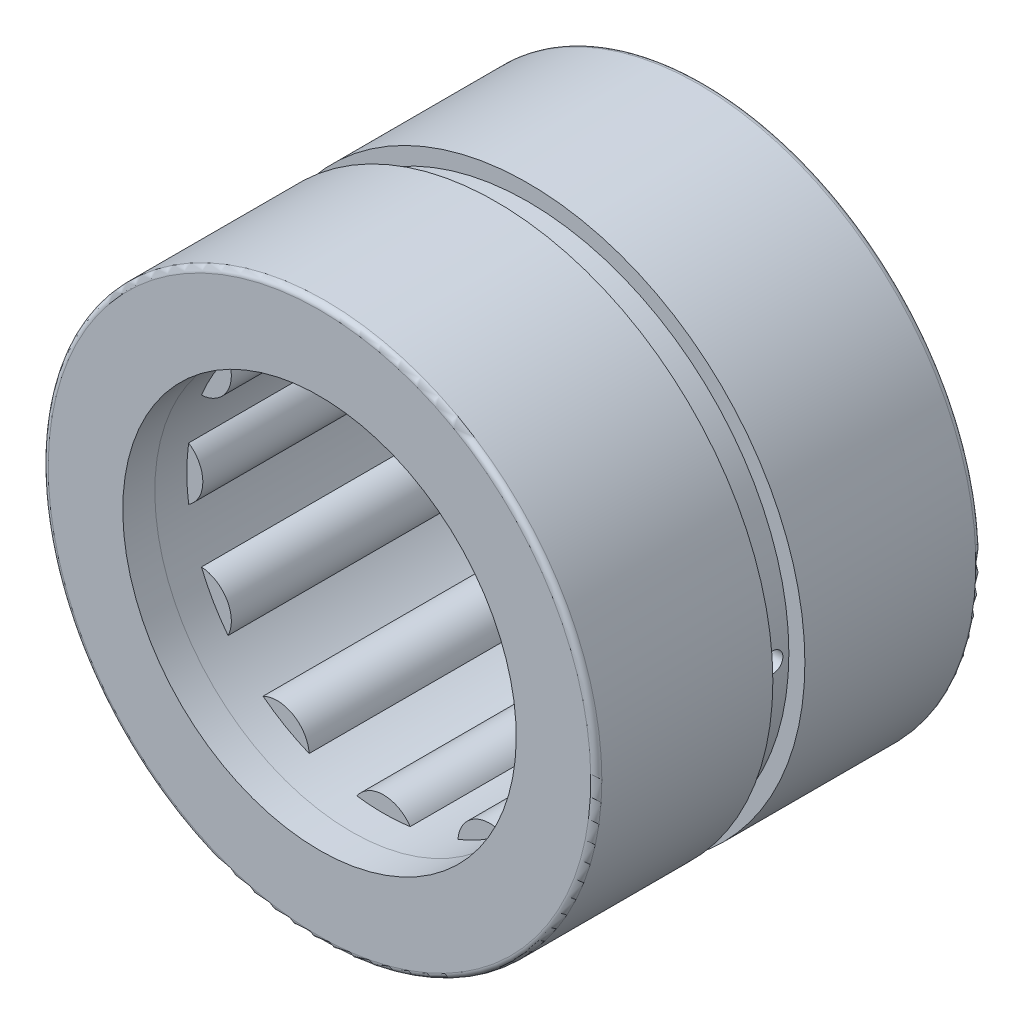
from build123d import *

# Parameters (mm, degrees)
SKETCH2_W           = 10.677333334
SKETCH2_H           = 0.998
SKETCH3_W           = 13.338666666
SKETCH3_H           = 0.332666666
CIRPATTERN1_COUNT   = 12
CIRPATTERN1_ANGLE   = 330
FILLET1_R           = 0.23
SKETCH5_R           = 10.269333333
SKETCH5_R_2         = 8.173333333
BOSS_EXTRUDE1_DEPTH = 13.338667
SKETCH2_4_W         = 10.677333334
SKETCH2_4_H         = 0.998
CIRPATTERN2_COUNT   = 12
SKETCH7_W           = 1.330666666
SKETCH7_H           = 0.665333333
SKETCH8_R           = 0.416666667
CUT_EXTRUDE2_DEPTH  = 12.5


with BuildPart() as part:
    # Sketch1 → Revolve1 (revolve)
    with BuildSketch(Plane(origin=(0, 0, 0), x_dir=(0, 0, -1), z_dir=(1, 0, 0))):
        Polygon((-8, 11.5), (8, 11.5), (8, 8.173333333), (6.669333333, 8.173333333), (6.669333333, 10.169333333), (-6.669333333, 10.169333333), (-6.669333333, 8.173333333), (-8, 8.173333333), align=None)
    revolve(axis=Axis((0, 0, 8), (0, 0, -1)))

    # Fillet1
    fillet1_edges = [part.edges().sort_by_distance(p)[0] for p in [
        (0, -11.5, 8),
        (0, -11.5, -8),
    ]]
    fillet(fillet1_edges, radius=FILLET1_R)

    # Sketch4 → Cut-Revolve1 (revolve, cut)
    with BuildSketch(Plane(origin=(0, 0, 0), x_dir=(0, 0, -1), z_dir=(1, 0, 0))):
        Polygon((-0.665333333, 11.5), (0, 10.834666667), (0.665333333, 11.5), align=None)
    revolve(axis=Axis((0, 0, 8), (0, 0, -1)), mode=Mode.SUBTRACT)

    # Sketch7 → Cut-Revolve4 (revolve, cut)
    with BuildSketch(Plane(origin=(0, 0, 0), x_dir=(0, 0, -1), z_dir=(1, 0, 0))):
        with Locations((0, 11.167333334)):
            Rectangle(SKETCH7_W, SKETCH7_H)
    revolve(axis=Axis((0, 0, 35.715394286), (0, 0, -1)), mode=Mode.SUBTRACT)

    # Sketch8 → Cut-Extrude2 (cut, through all)
    with BuildSketch(Plane(origin=(0, 0, 0), x_dir=(0, 0, -1), z_dir=(1, 0, 0))):
        Circle(SKETCH8_R)
    extrude(amount=CUT_EXTRUDE2_DEPTH, mode=Mode.SUBTRACT)


with BuildPart() as body_2:
    # Sketch2 → Revolve2 (revolve)
    with BuildSketch(Plane(origin=(0, 0, 0), x_dir=(0, 0, -1), z_dir=(1, 0, 0))):
        with Locations((0, 9.670333333)):
            Rectangle(SKETCH2_W, SKETCH2_H)
    revolve(axis=Axis((0, 8.838666667, 5.338666667), (0, 0, -1)))


with BuildPart() as body_3:
    # Sketch3 → Revolve3 (revolve)
    with BuildSketch(Plane(origin=(0, 0, 0), x_dir=(0, 0, -1), z_dir=(1, 0, 0))):
        with Locations((0, 9.005)):
            Rectangle(SKETCH3_W, SKETCH3_H)
    revolve(axis=Axis((0, 8.838666667, 6.669333333), (0, 0, -1)))


with BuildPart() as cirpattern1_1:
    # CirPattern1: pattern copy
    add(body_3.part.rotate(Axis((0, 0, -8), (0, 0, 1)), 1 * CIRPATTERN1_ANGLE / (CIRPATTERN1_COUNT - 1)))


with BuildPart() as cirpattern1_2:
    # CirPattern1: pattern copy
    add(body_3.part.rotate(Axis((0, 0, -8), (0, 0, 1)), 2 * CIRPATTERN1_ANGLE / (CIRPATTERN1_COUNT - 1)))


with BuildPart() as cirpattern1_3:
    # CirPattern1: pattern copy
    add(body_3.part.rotate(Axis((0, 0, -8), (0, 0, 1)), 3 * CIRPATTERN1_ANGLE / (CIRPATTERN1_COUNT - 1)))


with BuildPart() as cirpattern1_4:
    # CirPattern1: pattern copy
    add(body_3.part.rotate(Axis((0, 0, -8), (0, 0, 1)), 4 * CIRPATTERN1_ANGLE / (CIRPATTERN1_COUNT - 1)))


with BuildPart() as cirpattern1_5:
    # CirPattern1: pattern copy
    add(body_3.part.rotate(Axis((0, 0, -8), (0, 0, 1)), 5 * CIRPATTERN1_ANGLE / (CIRPATTERN1_COUNT - 1)))


with BuildPart() as cirpattern1_6:
    # CirPattern1: pattern copy
    add(body_3.part.rotate(Axis((0, 0, -8), (0, 0, 1)), 6 * CIRPATTERN1_ANGLE / (CIRPATTERN1_COUNT - 1)))


with BuildPart() as cirpattern1_7:
    # CirPattern1: pattern copy
    add(body_3.part.rotate(Axis((0, 0, -8), (0, 0, 1)), 7 * CIRPATTERN1_ANGLE / (CIRPATTERN1_COUNT - 1)))


with BuildPart() as cirpattern1_8:
    # CirPattern1: pattern copy
    add(body_3.part.rotate(Axis((0, 0, -8), (0, 0, 1)), 8 * CIRPATTERN1_ANGLE / (CIRPATTERN1_COUNT - 1)))


with BuildPart() as cirpattern1_9:
    # CirPattern1: pattern copy
    add(body_3.part.rotate(Axis((0, 0, -8), (0, 0, 1)), 9 * CIRPATTERN1_ANGLE / (CIRPATTERN1_COUNT - 1)))


with BuildPart() as cirpattern1_10:
    # CirPattern1: pattern copy
    add(body_3.part.rotate(Axis((0, 0, -8), (0, 0, 1)), 10 * CIRPATTERN1_ANGLE / (CIRPATTERN1_COUNT - 1)))


with BuildPart() as cirpattern1_11:
    # CirPattern1: pattern copy
    add(body_3.part.rotate(Axis((0, 0, -8), (0, 0, 1)), 11 * CIRPATTERN1_ANGLE / (CIRPATTERN1_COUNT - 1)))


with BuildPart() as cirpattern1_12:
    # CirPattern1: pattern copy
    add(body_2.part.rotate(Axis((0, 0, -8), (0, 0, 1)), 1 * CIRPATTERN1_ANGLE / (CIRPATTERN1_COUNT - 1)))


with BuildPart() as cirpattern1_13:
    # CirPattern1: pattern copy
    add(body_2.part.rotate(Axis((0, 0, -8), (0, 0, 1)), 2 * CIRPATTERN1_ANGLE / (CIRPATTERN1_COUNT - 1)))


with BuildPart() as cirpattern1_14:
    # CirPattern1: pattern copy
    add(body_2.part.rotate(Axis((0, 0, -8), (0, 0, 1)), 3 * CIRPATTERN1_ANGLE / (CIRPATTERN1_COUNT - 1)))


with BuildPart() as cirpattern1_15:
    # CirPattern1: pattern copy
    add(body_2.part.rotate(Axis((0, 0, -8), (0, 0, 1)), 4 * CIRPATTERN1_ANGLE / (CIRPATTERN1_COUNT - 1)))


with BuildPart() as cirpattern1_16:
    # CirPattern1: pattern copy
    add(body_2.part.rotate(Axis((0, 0, -8), (0, 0, 1)), 5 * CIRPATTERN1_ANGLE / (CIRPATTERN1_COUNT - 1)))


with BuildPart() as cirpattern1_17:
    # CirPattern1: pattern copy
    add(body_2.part.rotate(Axis((0, 0, -8), (0, 0, 1)), 6 * CIRPATTERN1_ANGLE / (CIRPATTERN1_COUNT - 1)))


with BuildPart() as cirpattern1_18:
    # CirPattern1: pattern copy
    add(body_2.part.rotate(Axis((0, 0, -8), (0, 0, 1)), 7 * CIRPATTERN1_ANGLE / (CIRPATTERN1_COUNT - 1)))


with BuildPart() as cirpattern1_19:
    # CirPattern1: pattern copy
    add(body_2.part.rotate(Axis((0, 0, -8), (0, 0, 1)), 8 * CIRPATTERN1_ANGLE / (CIRPATTERN1_COUNT - 1)))


with BuildPart() as cirpattern1_20:
    # CirPattern1: pattern copy
    add(body_2.part.rotate(Axis((0, 0, -8), (0, 0, 1)), 9 * CIRPATTERN1_ANGLE / (CIRPATTERN1_COUNT - 1)))


with BuildPart() as cirpattern1_21:
    # CirPattern1: pattern copy
    add(body_2.part.rotate(Axis((0, 0, -8), (0, 0, 1)), 10 * CIRPATTERN1_ANGLE / (CIRPATTERN1_COUNT - 1)))


with BuildPart() as cirpattern1_22:
    # CirPattern1: pattern copy
    add(body_2.part.rotate(Axis((0, 0, -8), (0, 0, 1)), 11 * CIRPATTERN1_ANGLE / (CIRPATTERN1_COUNT - 1)))


with BuildPart() as body_26:
    # Sketch5 → Boss-Extrude1 (new body)
    with BuildSketch(Plane.XY.offset(-6.669333333)):
        Circle(SKETCH5_R)
        Circle(SKETCH5_R_2, mode=Mode.SUBTRACT)
    extrude(amount=BOSS_EXTRUDE1_DEPTH)

    # Sketch2_4 → Cut-Revolve3 (revolve, cut)
    with BuildSketch(Plane(origin=(0, 0, 0), x_dir=(0, 0, -1), z_dir=(1, 0, 0))):
        with Locations((0, 9.670333333)):
            Rectangle(SKETCH2_4_W, SKETCH2_4_H)
    cut_revolve3 = revolve(axis=Axis((0, 8.838666667, 5.338666667), (0, 0, -1)), mode=Mode.SUBTRACT)

    # CirPattern2: Cut-Revolve3 ×12 about axis
    cirpattern2_axis = Axis((0, 0, 0), (0, 0, 1))
    for i in range(1, CIRPATTERN2_COUNT):
        add(cut_revolve3.rotate(cirpattern2_axis, i * 360 / CIRPATTERN2_COUNT), mode=Mode.SUBTRACT)


solid = Compound([part.part, body_2.part, body_3.part, cirpattern1_1.part, cirpattern1_2.part, cirpattern1_3.part, cirpattern1_4.part, cirpattern1_5.part, cirpattern1_6.part, cirpattern1_7.part, cirpattern1_8.part, cirpattern1_9.part, cirpattern1_10.part, cirpattern1_11.part, cirpattern1_12.part, cirpattern1_13.part, cirpattern1_14.part, cirpattern1_15.part, cirpattern1_16.part, cirpattern1_17.part, cirpattern1_18.part, cirpattern1_19.part, cirpattern1_20.part, cirpattern1_21.part, cirpattern1_22.part, body_26.part])
